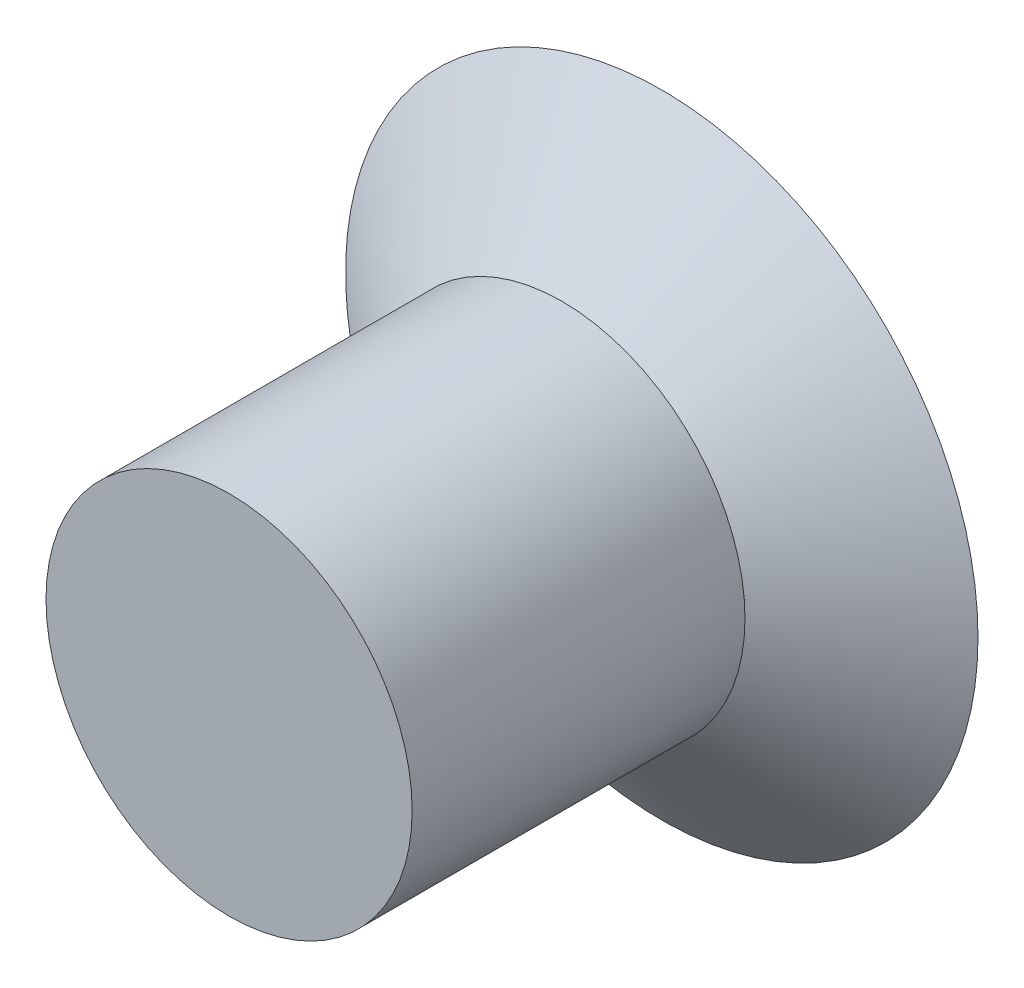
from build123d import *

# Parameters (mm, degrees)
SKETCH2_R           = 5.5
SKETCH1_R           = 9.5
SKETCH2_2_R         = 5.5
BOSS_EXTRUDE1_DEPTH = 10


with BuildPart() as part:
    # Sketch2 → Loft1 section 0
    with BuildSketch(Plane.XY.offset(3)):
        Circle(SKETCH2_R)
    # Sketch1 → Loft1 section 1
    with BuildSketch(Plane.XY):
        Circle(SKETCH1_R)
    loft()

    # Sketch2_2 → Boss-Extrude1 (add)
    with BuildSketch(Plane.XY.offset(3)):
        Circle(SKETCH2_2_R)
    extrude(amount=BOSS_EXTRUDE1_DEPTH)


solid = part.part
